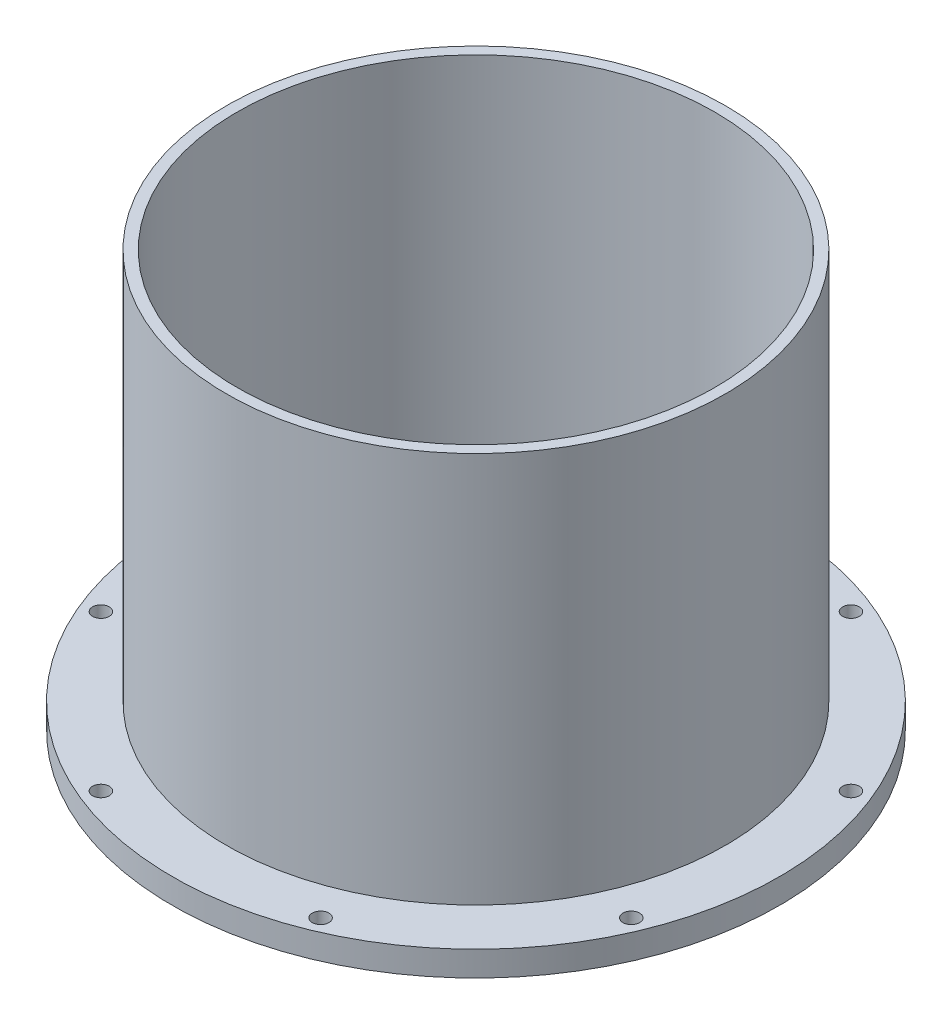
from build123d import *

# Parameters (mm, degrees)
CUT_EXTRUDE1_START = -16
SKETCH2_R          = 5
CUT_EXTRUDE1_DEPTH = 252
CIRPATTERN1_COUNT  = 8


with BuildPart() as part:
    # Sketch1 → Revolve1 (revolve)
    with BuildSketch(Plane.XY):
        Polygon((143.5, 250), (143.5, 0), (182.5, 0), (182.5, 15), (150, 15), (150, 250), align=None)
    revolve(axis=Axis((0, 0, 0), (0, 1, 0)))

    # Sketch2 → Cut-Extrude1 (cut)
    with BuildSketch(Plane(origin=(0, 15, 0), x_dir=(1, 0, 0), z_dir=(0, 1, 0)).offset(CUT_EXTRUDE1_START)):
        with Locations((159.369219358, 66.012892083)):
            Circle(SKETCH2_R)
    cut_extrude1 = extrude(amount=CUT_EXTRUDE1_DEPTH, mode=Mode.SUBTRACT)

    # CirPattern1: Cut-Extrude1 ×8 about axis
    cirpattern1_axis = Axis((0, 0, 0), (0, 1, 0))
    for i in range(1, CIRPATTERN1_COUNT):
        add(cut_extrude1.rotate(cirpattern1_axis, i * 360 / CIRPATTERN1_COUNT), mode=Mode.SUBTRACT)


solid = part.part
